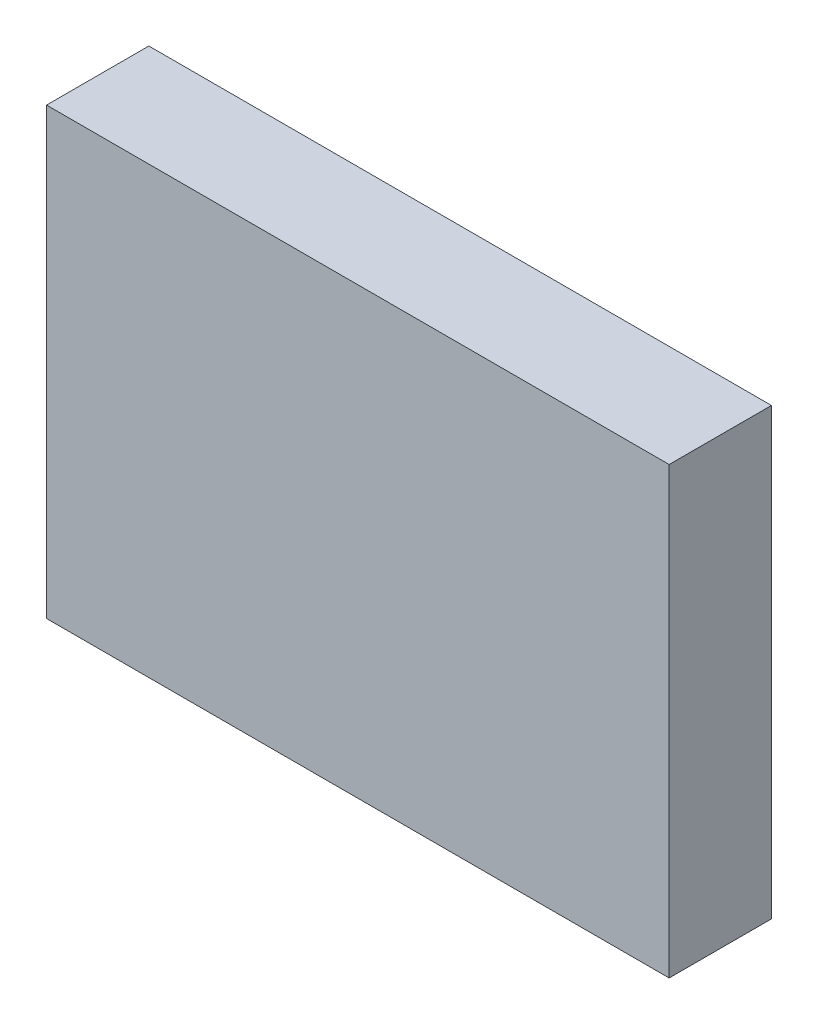
from build123d import *

# Parameters (mm, degrees)
SKETCH_1_W      = 14
SKETCH_1_H      = 10
EXTRUDE_1_DEPTH = 2.3


with BuildPart() as part:
    # 草图1 → 凸台-拉伸1 (new body)
    with BuildSketch(Plane.XY):
        with Locations((43.445993577, 24.625296734)):
            Rectangle(SKETCH_1_W, SKETCH_1_H)
    extrude(amount=EXTRUDE_1_DEPTH)


solid = part.part
